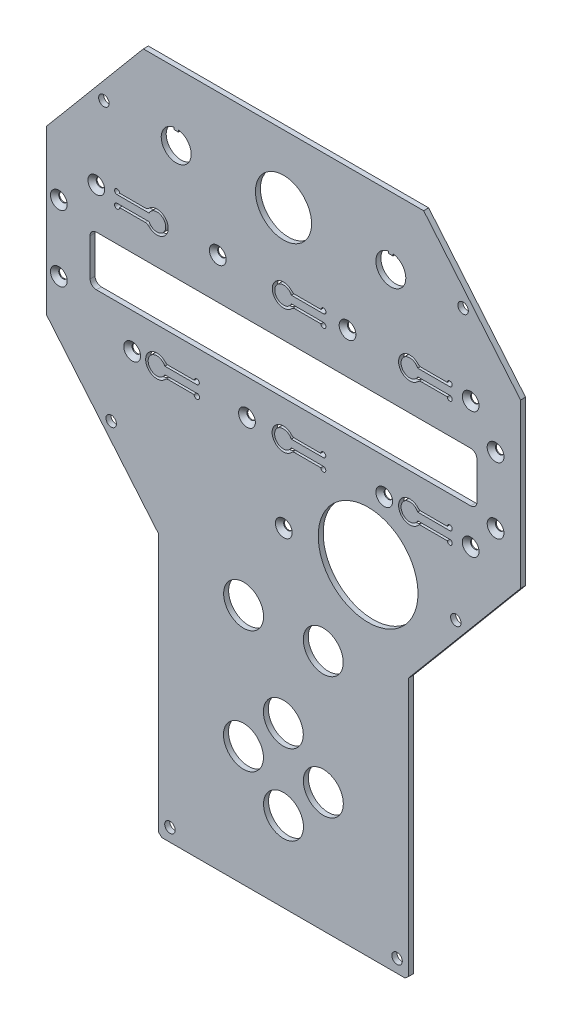
from build123d import *

# Parameters (mm, degrees)
RESSALTO_EXTRUS_O1_DEPTH                      = 2
CORTE_EXTRUS_O1_REACH                         = 4
ESBO_O2_R                                     = 2.1
CORTE_EXTRUS_O2_REACH                         = 4
CORTE_EXTRUS_O3_REACH                         = 4
ESBO_O4_R                                     = 20
CORTE_EXTRUS_O4_REACH                         = 4
ESBO_O5_R                                     = 8
ESBO_O5_R_2                                   = 11.25
ESCAREADO_PARA_PARAFUSO_ALLEN_SEXTAV_2_COUNT  = 2
ESCAREADO_PARA_PARAFUSO_ALLEN_SEXTAV_2_PITCH  = 26.5
ESCAREADO_PARA_PARAFUSO_ALLEN_SEXTAV_3_COUNT  = 2
ESCAREADO_PARA_PARAFUSO_ALLEN_SEXTAV_3_PITCH  = 47.918783057
ESCAREADO_PARA_PARAFUSO_ALLEN_SEXTAV_4_COUNT  = 2
ESCAREADO_PARA_PARAFUSO_ALLEN_SEXTAV_4_PITCH  = 84.354894452
ESCAREADO_PARA_PARAFUSO_ALLEN_SEXTAV_5_COUNT  = 2
ESCAREADO_PARA_PARAFUSO_ALLEN_SEXTAV_5_PITCH  = 135.769067452
ESCAREADO_PARA_PARAFUSO_ALLEN_SEXTAV_6_COUNT  = 2
ESCAREADO_PARA_PARAFUSO_ALLEN_SEXTAV_6_PITCH  = 176.995056428
ESCAREADO_PARA_PARAFUSO_ALLEN_SEXTAV_7_COUNT  = 2
ESCAREADO_PARA_PARAFUSO_ALLEN_SEXTAV_7_PITCH  = 175
ESCAREADO_PARA_PARAFUSO_ALLEN_SEXTAV_8_COUNT  = 2
ESCAREADO_PARA_PARAFUSO_ALLEN_SEXTAV_8_PITCH  = 116.384068539
ESCAREADO_PARA_PARAFUSO_ALLEN_SEXTAV_9_COUNT  = 2
ESCAREADO_PARA_PARAFUSO_ALLEN_SEXTAV_9_PITCH  = 64.945475466
ESCAREADO_PARA_PARAFUSO_ALLEN_SEXTAV_10_COUNT = 2
ESCAREADO_PARA_PARAFUSO_ALLEN_SEXTAV_10_PITCH = 113.39334618
CORTE_EXTRUS_O5_DEPTH                         = 10
FILETE1_R                                     = 2
ESCAREADO_PARA_PARAFUSO_ALLEN_SEXTAV_12_COUNT = 2
ESCAREADO_PARA_PARAFUSO_ALLEN_SEXTAV_12_PITCH = 150
ESCAREADO_PARA_PARAFUSO_ALLEN_SEXTAV_13_COUNT = 2
ESCAREADO_PARA_PARAFUSO_ALLEN_SEXTAV_13_PITCH = 158.297944738


with BuildPart() as part:
    # Esboço1 → Ressalto-extrusão1 (new body)
    with BuildSketch(Plane.XY):
        Polygon((55.321046002, 133.809611411), (-57.006999458, 133.809611411), (-95.842976728, 87.526695978), (-95.842976728, 22.140182404), (-50.842976728, -31.488729263), (-50.842976728, -135.082673958), (-49.522853837, -136.190388589), (47.836900381, -136.190388589), (49.157023272, -135.082673958), (49.157023272, -31.488729263), (94.157023272, 22.140182404), (94.157023272, 87.526695978), align=None)
    extrude(amount=RESSALTO_EXTRUS_O1_DEPTH)

    # Esboço2 → Corte-extrusão1 (cut, up to next)
    with BuildSketch(Plane.XY.offset(2), mode=Mode.PRIVATE) as corte_extrus_o1_sk1:
        with Locations((-72.814392548, 107.949888211)):
            Circle(ESBO_O2_R)
    corte_extrus_o1_tool1 = extrude(corte_extrus_o1_sk1.sketch, amount=-CORTE_EXTRUS_O1_REACH, mode=Mode.PRIVATE) & part.part
    add(corte_extrus_o1_tool1.solids().sort_by_distance((-72.814393, 107.949888, 2))[0], mode=Mode.SUBTRACT)
    # Esboço2 → Corte-extrusão1 (cut, up to next)
    with BuildSketch(Plane.XY.offset(2), mode=Mode.PRIVATE) as corte_extrus_o1_sk2:
        with Locations((-46.342976728, -130.964393909)):
            Circle(ESBO_O2_R)
    corte_extrus_o1_tool2 = extrude(corte_extrus_o1_sk2.sketch, amount=-CORTE_EXTRUS_O1_REACH, mode=Mode.PRIVATE) & part.part
    add(corte_extrus_o1_tool2.solids().sort_by_distance((-46.342977, -130.964394, 2))[0], mode=Mode.SUBTRACT)
    # Esboço2 → Corte-extrusão1 (cut, up to next)
    with BuildSketch(Plane.XY.offset(2), mode=Mode.PRIVATE) as corte_extrus_o1_sk3:
        with Locations((44.657023272, -130.964393909)):
            Circle(ESBO_O2_R)
    corte_extrus_o1_tool3 = extrude(corte_extrus_o1_sk3.sketch, amount=-CORTE_EXTRUS_O1_REACH, mode=Mode.PRIVATE) & part.part
    add(corte_extrus_o1_tool3.solids().sort_by_distance((44.657023, -130.964394, 2))[0], mode=Mode.SUBTRACT)
    # Esboço2 → Corte-extrusão1 (cut, up to next)
    with BuildSketch(Plane.XY.offset(2), mode=Mode.PRIVATE) as corte_extrus_o1_sk4:
        with Locations((71.128439092, 107.949888211)):
            Circle(ESBO_O2_R)
    corte_extrus_o1_tool4 = extrude(corte_extrus_o1_sk4.sketch, amount=-CORTE_EXTRUS_O1_REACH, mode=Mode.PRIVATE) & part.part
    add(corte_extrus_o1_tool4.solids().sort_by_distance((71.128439, 107.949888, 2))[0], mode=Mode.SUBTRACT)
    # Esboço2 → Corte-extrusão1 (cut, up to next)
    with BuildSketch(Plane.XY.offset(2), mode=Mode.PRIVATE) as corte_extrus_o1_sk5:
        with Locations((-69.895776734, -1.781729186)):
            Circle(ESBO_O2_R)
    corte_extrus_o1_tool5 = extrude(corte_extrus_o1_sk5.sketch, amount=-CORTE_EXTRUS_O1_REACH, mode=Mode.PRIVATE) & part.part
    add(corte_extrus_o1_tool5.solids().sort_by_distance((-69.895777, -1.781729, 2))[0], mode=Mode.SUBTRACT)
    # Esboço2 → Corte-extrusão1 (cut, up to next)
    with BuildSketch(Plane.XY.offset(2), mode=Mode.PRIVATE) as corte_extrus_o1_sk6:
        with Locations((68.209823278, -1.781729186)):
            Circle(ESBO_O2_R)
    corte_extrus_o1_tool6 = extrude(corte_extrus_o1_sk6.sketch, amount=-CORTE_EXTRUS_O1_REACH, mode=Mode.PRIVATE) & part.part
    add(corte_extrus_o1_tool6.solids().sort_by_distance((68.209823, -1.781729, 2))[0], mode=Mode.SUBTRACT)

    # Esboço3 → Corte-extrusão2 (cut, up to next)
    with BuildSketch(Plane.XY.offset(2), mode=Mode.PRIVATE) as corte_extrus_o2_sk1:
        with BuildLine():
            Line((-75.842976728, 40.809611411), (74.157023272, 40.809611411))
            ThreePointArc((74.157023272, 40.809611411), (75.924790225, 41.541844458), (76.657023272, 43.309611411))
            Line((76.657023272, 43.309611411), (76.657023272, 58.309611411))
            ThreePointArc((76.657023272, 58.309611411), (75.924790225, 60.077378364), (74.157023272, 60.809611411))
            Line((74.157023272, 60.809611411), (-75.842976728, 60.809611411))
            ThreePointArc((-75.842976728, 60.809611411), (-77.610743681, 60.077378364), (-78.342976728, 58.309611411))
            Line((-78.342976728, 58.309611411), (-78.342976728, 43.309611411))
            ThreePointArc((-78.342976728, 43.309611411), (-77.610743681, 41.541844458), (-75.842976728, 40.809611411))
        make_face()
    corte_extrus_o2_tool1 = extrude(corte_extrus_o2_sk1.sketch, amount=-CORTE_EXTRUS_O2_REACH, mode=Mode.PRIVATE) & part.part
    add(corte_extrus_o2_tool1.solids().sort_by_distance((-0.842977, 50.809611, 2))[0], mode=Mode.SUBTRACT)

    # Esboço4 → Corte-extrusão3 (cut, up to next)
    with BuildSketch(Plane.XY.offset(2), mode=Mode.PRIVATE) as corte_extrus_o3_sk1:
        with Locations((33.056325833, -0.190388589)):
            Circle(ESBO_O4_R)
    corte_extrus_o3_tool1 = extrude(corte_extrus_o3_sk1.sketch, amount=-CORTE_EXTRUS_O3_REACH, mode=Mode.PRIVATE) & part.part
    add(corte_extrus_o3_tool1.solids().sort_by_distance((33.056326, -0.190389, 2))[0], mode=Mode.SUBTRACT)

    # Esboço5 → Corte-extrusão4 (cut, up to next)
    with BuildSketch(Plane.XY.offset(2), mode=Mode.PRIVATE) as corte_extrus_o4_sk1:
        with Locations((-16.894876728, -88.105888589)):
            Circle(ESBO_O5_R)
    corte_extrus_o4_tool1 = extrude(corte_extrus_o4_sk1.sketch, amount=-CORTE_EXTRUS_O4_REACH, mode=Mode.PRIVATE) & part.part
    add(corte_extrus_o4_tool1.solids().sort_by_distance((-16.894877, -88.105889, 2))[0], mode=Mode.SUBTRACT)
    # Esboço5 → Corte-extrusão4 (cut, up to next)
    with BuildSketch(Plane.XY.offset(2), mode=Mode.PRIVATE) as corte_extrus_o4_sk2:
        with Locations((15.122923272, -88.105888589)):
            Circle(ESBO_O5_R)
    corte_extrus_o4_tool2 = extrude(corte_extrus_o4_sk2.sketch, amount=-CORTE_EXTRUS_O4_REACH, mode=Mode.PRIVATE) & part.part
    add(corte_extrus_o4_tool2.solids().sort_by_distance((15.122923, -88.105889, 2))[0], mode=Mode.SUBTRACT)
    # Esboço5 → Corte-extrusão4 (cut, up to next)
    with BuildSketch(Plane.XY.offset(2), mode=Mode.PRIVATE) as corte_extrus_o4_sk3:
        with Locations((-0.842976728, -104.141188589)):
            Circle(ESBO_O5_R)
    corte_extrus_o4_tool3 = extrude(corte_extrus_o4_sk3.sketch, amount=-CORTE_EXTRUS_O4_REACH, mode=Mode.PRIVATE) & part.part
    add(corte_extrus_o4_tool3.solids().sort_by_distance((-0.842977, -104.141189, 2))[0], mode=Mode.SUBTRACT)
    # Esboço5 → Corte-extrusão4 (cut, up to next)
    with BuildSketch(Plane.XY.offset(2), mode=Mode.PRIVATE) as corte_extrus_o4_sk4:
        with Locations((-0.909676728, -72.123388589)):
            Circle(ESBO_O5_R)
    corte_extrus_o4_tool4 = extrude(corte_extrus_o4_sk4.sketch, amount=-CORTE_EXTRUS_O4_REACH, mode=Mode.PRIVATE) & part.part
    add(corte_extrus_o4_tool4.solids().sort_by_distance((-0.909677, -72.123389, 2))[0], mode=Mode.SUBTRACT)
    # Esboço5 → Corte-extrusão4 (cut, up to next)
    with BuildSketch(Plane.XY.offset(2), mode=Mode.PRIVATE) as corte_extrus_o4_sk5:
        with Locations((-16.835676728, -39.139288589)):
            Circle(ESBO_O5_R)
    corte_extrus_o4_tool5 = extrude(corte_extrus_o4_sk5.sketch, amount=-CORTE_EXTRUS_O4_REACH, mode=Mode.PRIVATE) & part.part
    add(corte_extrus_o4_tool5.solids().sort_by_distance((-16.835677, -39.139289, 2))[0], mode=Mode.SUBTRACT)
    # Esboço5 → Corte-extrusão4 (cut, up to next)
    with BuildSketch(Plane.XY.offset(2), mode=Mode.PRIVATE) as corte_extrus_o4_sk6:
        with Locations((15.081923272, -39.110788589)):
            Circle(ESBO_O5_R)
    corte_extrus_o4_tool6 = extrude(corte_extrus_o4_sk6.sketch, amount=-CORTE_EXTRUS_O4_REACH, mode=Mode.PRIVATE) & part.part
    add(corte_extrus_o4_tool6.solids().sort_by_distance((15.081923, -39.110789, 2))[0], mode=Mode.SUBTRACT)
    # Esboço5 → Corte-extrusão4 (cut, up to next)
    with BuildSketch(Plane.XY.offset(2), mode=Mode.PRIVATE) as corte_extrus_o4_sk7:
        with Locations((-0.842976728, 106.809611411)):
            Circle(ESBO_O5_R_2)
    corte_extrus_o4_tool7 = extrude(corte_extrus_o4_sk7.sketch, amount=-CORTE_EXTRUS_O4_REACH, mode=Mode.PRIVATE) & part.part
    add(corte_extrus_o4_tool7.solids().sort_by_distance((-0.842977, 106.809611, 2))[0], mode=Mode.SUBTRACT)
    # Esboço5 → Corte-extrusão4 (cut, up to next)
    with BuildSketch(Plane.XY.offset(2), mode=Mode.PRIVATE) as corte_extrus_o4_sk8:
        with BuildLine():
            Line((-44.742976728, 112.741727391), (-44.742976728, 111.941727391))
            Line((-44.742976728, 111.941727391), (-42.942976728, 111.941727391))
            Line((-42.942976728, 111.941727391), (-42.942976728, 112.741727391))
            ThreePointArc((-42.942976728, 112.741727391), (-43.842976728, 100.809611411), (-44.742976728, 112.741727391))
        make_face()
    corte_extrus_o4_tool8 = extrude(corte_extrus_o4_sk8.sketch, amount=-CORTE_EXTRUS_O4_REACH, mode=Mode.PRIVATE) & part.part
    add(corte_extrus_o4_tool8.solids().sort_by_distance((-43.842977, 106.733858, 2))[0], mode=Mode.SUBTRACT)
    # Esboço5 → Corte-extrusão4 (cut, up to next)
    with BuildSketch(Plane.XY.offset(2), mode=Mode.PRIVATE) as corte_extrus_o4_sk9:
        with BuildLine():
            Line((41.257023272, 112.741727391), (41.257023272, 111.941727391))
            Line((41.257023272, 111.941727391), (43.057023272, 111.941727391))
            Line((43.057023272, 111.941727391), (43.057023272, 112.741727391))
            ThreePointArc((43.057023272, 112.741727391), (42.157023272, 100.809611411), (41.257023272, 112.741727391))
        make_face()
    corte_extrus_o4_tool9 = extrude(corte_extrus_o4_sk9.sketch, amount=-CORTE_EXTRUS_O4_REACH, mode=Mode.PRIVATE) & part.part
    add(corte_extrus_o4_tool9.solids().sort_by_distance((42.157023, 106.733858, 2))[0], mode=Mode.SUBTRACT)

    # Esboço11 → Escareado para parafuso Allen sextavado (revolve, cut)
    with BuildSketch(Plane(origin=(-90.868976728, 64.471011411, 2), x_dir=(0, -1, 0), z_dir=(1, 0, 0))):
        Polygon((0, 0), (0, 2), (1.7, 2), (1.7, 1.66), (3.36, 0), align=None)
    escareado_para_parafuso_allen_sextavado = revolve(axis=Axis((-90.868976728, 64.471011411, 8.35), (0, 0, -1)), mode=Mode.SUBTRACT)

    # Escareado para parafuso Allen sextav 2: Escareado para parafuso Allen sextavado ×2
    with Locations(*[(0, -i * ESCAREADO_PARA_PARAFUSO_ALLEN_SEXTAV_2_PITCH, 0) for i in range(1, ESCAREADO_PARA_PARAFUSO_ALLEN_SEXTAV_2_COUNT)]):
        add(escareado_para_parafuso_allen_sextavado, mode=Mode.SUBTRACT)

    # Escareado para parafuso Allen sextav 3: Escareado para parafuso Allen sextavado ×2
    with Locations(*[Vector(0.613251976, -0.789887343, 0) * (i * ESCAREADO_PARA_PARAFUSO_ALLEN_SEXTAV_3_PITCH) for i in range(1, ESCAREADO_PARA_PARAFUSO_ALLEN_SEXTAV_3_COUNT)]):
        add(escareado_para_parafuso_allen_sextavado, mode=Mode.SUBTRACT)

    # Escareado para parafuso Allen sextav 4: Escareado para parafuso Allen sextavado ×2
    with Locations(*[Vector(0.893680068, -0.448704731, 0) * (i * ESCAREADO_PARA_PARAFUSO_ALLEN_SEXTAV_4_PITCH) for i in range(1, ESCAREADO_PARA_PARAFUSO_ALLEN_SEXTAV_4_COUNT)]):
        add(escareado_para_parafuso_allen_sextavado, mode=Mode.SUBTRACT)

    # Escareado para parafuso Allen sextav 5: Escareado para parafuso Allen sextavado ×2
    with Locations(*[Vector(0.960353411, -0.278785447, 0) * (i * ESCAREADO_PARA_PARAFUSO_ALLEN_SEXTAV_5_PITCH) for i in range(1, ESCAREADO_PARA_PARAFUSO_ALLEN_SEXTAV_5_COUNT)]):
        add(escareado_para_parafuso_allen_sextavado, mode=Mode.SUBTRACT)

    # Escareado para parafuso Allen sextav 6: Escareado para parafuso Allen sextavado ×2
    with Locations(*[Vector(0.98872818, -0.149721696, 0) * (i * ESCAREADO_PARA_PARAFUSO_ALLEN_SEXTAV_6_PITCH) for i in range(1, ESCAREADO_PARA_PARAFUSO_ALLEN_SEXTAV_6_COUNT)]):
        add(escareado_para_parafuso_allen_sextavado, mode=Mode.SUBTRACT)

    # Escareado para parafuso Allen sextav 7: Escareado para parafuso Allen sextavado ×2
    with Locations(*[(i * ESCAREADO_PARA_PARAFUSO_ALLEN_SEXTAV_7_PITCH, 0, 0) for i in range(1, ESCAREADO_PARA_PARAFUSO_ALLEN_SEXTAV_7_COUNT)]):
        add(escareado_para_parafuso_allen_sextavado, mode=Mode.SUBTRACT)

    # Escareado para parafuso Allen sextav 8: Escareado para parafuso Allen sextavado ×2
    with Locations(*[Vector(0.994001416, 0.109367203, 0) * (i * ESCAREADO_PARA_PARAFUSO_ALLEN_SEXTAV_8_PITCH) for i in range(1, ESCAREADO_PARA_PARAFUSO_ALLEN_SEXTAV_8_COUNT)]):
        add(escareado_para_parafuso_allen_sextavado, mode=Mode.SUBTRACT)

    # Escareado para parafuso Allen sextav 9: Escareado para parafuso Allen sextavado ×2
    with Locations(*[Vector(0.98060609, 0.195989019, 0) * (i * ESCAREADO_PARA_PARAFUSO_ALLEN_SEXTAV_9_PITCH) for i in range(1, ESCAREADO_PARA_PARAFUSO_ALLEN_SEXTAV_9_COUNT)]):
        add(escareado_para_parafuso_allen_sextavado, mode=Mode.SUBTRACT)

    # Escareado para parafuso Allen sextav 10: Escareado para parafuso Allen sextavado ×2
    with Locations(*[Vector(0.794899268, -0.606741423, 0) * (i * ESCAREADO_PARA_PARAFUSO_ALLEN_SEXTAV_10_PITCH) for i in range(1, ESCAREADO_PARA_PARAFUSO_ALLEN_SEXTAV_10_COUNT)]):
        add(escareado_para_parafuso_allen_sextavado, mode=Mode.SUBTRACT)

    # Esboço12 → Corte-extrusão5 (cut)
    with BuildSketch(Plane.XY.offset(2)):
        with BuildLine():
            Line((52.929300932, 28.019611411), (65.767023272, 28.019611411))
            ThreePointArc((65.767023272, 28.019611411), (66.474130053, 29.726718193), (64.767023272, 29.019611411))
            Line((64.767023272, 29.019611411), (53.508680659, 29.019611411))
            ThreePointArc((53.508680659, 29.019611411), (45.267023272, 26.519611411), (53.508680659, 24.019611411))
            Line((53.508680659, 24.019611411), (64.767023272, 24.019611411))
            ThreePointArc((64.767023272, 24.019611411), (66.474130053, 23.31250463), (65.767023272, 25.019611411))
            Line((65.767023272, 25.019611411), (52.929300932, 25.019611411))
            ThreePointArc((52.929300932, 25.019611411), (46.267023272, 26.519611411), (52.929300932, 28.019611411))
        make_face()
        with BuildLine():
            Line((2.259300932, 28.019611411), (15.097023272, 28.019611411))
            ThreePointArc((15.097023272, 28.019611411), (15.804130053, 29.726718193), (14.097023272, 29.019611411))
            Line((14.097023272, 29.019611411), (2.838680659, 29.019611411))
            ThreePointArc((2.838680659, 29.019611411), (-5.402976728, 26.519611411), (2.838680659, 24.019611411))
            Line((2.838680659, 24.019611411), (14.097023272, 24.019611411))
            ThreePointArc((14.097023272, 24.019611411), (15.804130053, 23.31250463), (15.097023272, 25.019611411))
            Line((15.097023272, 25.019611411), (2.259300932, 25.019611411))
            ThreePointArc((2.259300932, 25.019611411), (-4.402976728, 26.519611411), (2.259300932, 28.019611411))
        make_face()
        with BuildLine():
            Line((-48.410699068, 28.019611411), (-35.572976728, 28.019611411))
            ThreePointArc((-35.572976728, 28.019611411), (-34.865869947, 29.726718193), (-36.572976728, 29.019611411))
            Line((-36.572976728, 29.019611411), (-47.831319341, 29.019611411))
            ThreePointArc((-47.831319341, 29.019611411), (-56.072976728, 26.519611411), (-47.831319341, 24.019611411))
            Line((-47.831319341, 24.019611411), (-36.653425887, 24.019611411))
            ThreePointArc((-36.653425887, 24.019611411), (-34.675928196, 23.417386939), (-35.982085986, 25.019611411))
            Line((-35.982085986, 25.019611411), (-48.410699068, 25.019611411))
            ThreePointArc((-48.410699068, 25.019611411), (-55.072976728, 26.519611411), (-48.410699068, 28.019611411))
        make_face()
        with BuildLine():
            Line((2.329300932, 77.979611411), (15.167023272, 77.979611411))
            ThreePointArc((15.167023272, 77.979611411), (15.874130053, 79.686718193), (14.167023272, 78.979611411))
            Line((14.167023272, 78.979611411), (2.908680659, 78.979611411))
            ThreePointArc((2.908680659, 78.979611411), (-5.332976728, 76.479611411), (2.908680659, 73.979611411))
            Line((2.908680659, 73.979611411), (14.167023272, 73.979611411))
            ThreePointArc((14.167023272, 73.979611411), (15.874130053, 73.27250463), (15.167023272, 74.979611411))
            Line((15.167023272, 74.979611411), (2.329300932, 74.979611411))
            ThreePointArc((2.329300932, 74.979611411), (-4.332976728, 76.479611411), (2.329300932, 77.979611411))
        make_face()
        with BuildLine():
            Line((52.929300932, 77.979611411), (65.767023272, 77.979611411))
            ThreePointArc((65.767023272, 77.979611411), (66.474130053, 79.686718193), (64.767023272, 78.979611411))
            Line((64.767023272, 78.979611411), (53.508680659, 78.979611411))
            ThreePointArc((53.508680659, 78.979611411), (45.267023272, 76.479611411), (53.508680659, 73.979611411))
            Line((53.508680659, 73.979611411), (64.767023272, 73.979611411))
            ThreePointArc((64.767023272, 73.979611411), (66.474130053, 73.27250463), (65.767023272, 74.979611411))
            Line((65.767023272, 74.979611411), (52.929300932, 74.979611411))
            ThreePointArc((52.929300932, 74.979611411), (46.267023272, 76.479611411), (52.929300932, 77.979611411))
        make_face()
        with BuildLine():
            Line((-54.695254388, 77.979611411), (-67.532976728, 77.979611411))
            ThreePointArc((-67.532976728, 77.979611411), (-68.240083509, 79.686718193), (-66.532976728, 78.979611411))
            Line((-66.532976728, 78.979611411), (-55.274634115, 78.979611411))
            ThreePointArc((-55.274634115, 78.979611411), (-47.032976728, 76.479611411), (-55.274634115, 73.979611411))
            Line((-55.274634115, 73.979611411), (-66.532976728, 73.979611411))
            ThreePointArc((-66.532976728, 73.979611411), (-68.240083509, 73.27250463), (-67.532976728, 74.979611411))
            Line((-67.532976728, 74.979611411), (-54.695254388, 74.979611411))
            ThreePointArc((-54.695254388, 74.979611411), (-48.032976728, 76.479611411), (-54.695254388, 77.979611411))
        make_face()
    extrude(amount=-CORTE_EXTRUS_O5_DEPTH, mode=Mode.SUBTRACT)

    # Filete1
    filete1_edges = [part.edges().sort_by_distance(p)[0] for p in [
        (53.508680659, 29.019611411, 1),
        (-47.831319341, 24.019611411, 1),
        (-47.831319341, 29.019611411, 1),
        (-55.274634115, 78.979611411, 1),
        (-55.274634115, 73.979611411, 1),
        (2.908680659, 73.979611411, 1),
        (2.908680659, 78.979611411, 1),
        (53.508680659, 73.979611411, 1),
        (53.508680659, 78.979611411, 1),
        (2.838680659, 24.019611411, 1),
        (2.838680659, 29.019611411, 1),
    ]]
    fillet(filete1_edges, radius=FILETE1_R)

    # Esboço14 → Escareado para parafuso Allen sextav 11 (revolve, cut)
    with BuildSketch(Plane(origin=(-75.842976728, 77.199611411, 2), x_dir=(0, -1, 0), z_dir=(1, 0, 0))):
        Polygon((0, 0), (0, 2), (1.7, 2), (1.7, 1.66), (3.36, 0), align=None)
    escareado_para_parafuso_allen_sextav_11 = revolve(axis=Axis((-75.842976728, 77.199611411, 8.35), (0, 0, -1)), mode=Mode.SUBTRACT)

    # Escareado para parafuso Allen sextav 12: Escareado para parafuso Allen sextav 11 ×2
    with Locations(*[(i * ESCAREADO_PARA_PARAFUSO_ALLEN_SEXTAV_12_PITCH, 0, 0) for i in range(1, ESCAREADO_PARA_PARAFUSO_ALLEN_SEXTAV_12_COUNT)]):
        add(escareado_para_parafuso_allen_sextav_11, mode=Mode.SUBTRACT)

    # Escareado para parafuso Allen sextav 13: Escareado para parafuso Allen sextav 11 ×2
    with Locations(*[Vector(0.947580212, -0.319517984, 0) * (i * ESCAREADO_PARA_PARAFUSO_ALLEN_SEXTAV_13_PITCH) for i in range(1, ESCAREADO_PARA_PARAFUSO_ALLEN_SEXTAV_13_COUNT)]):
        add(escareado_para_parafuso_allen_sextav_11, mode=Mode.SUBTRACT)


solid = part.part
